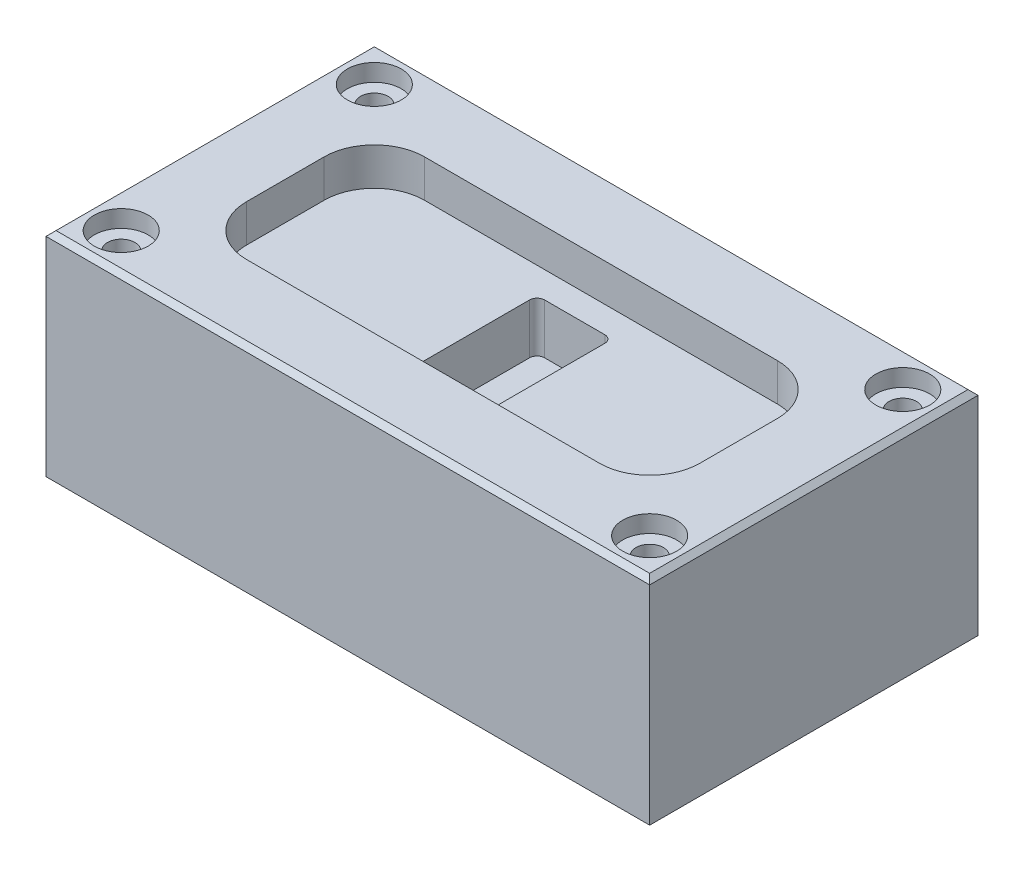
from build123d import *

# Parameters (mm, degrees)
SKETCH3_W                                = 240.765342714
SKETCH3_H                                = 130.947670476
BOSS_EXTRUDE2_DEPTH                      = 85
SKETCH4_W                                = 180.765342714
SKETCH4_H                                = 70.947670476
CUT_EXTRUDE1_DEPTH                       = 15
CBORE_FOR_M10_HEX_HEAD_BOLT1_D           = 11
CBORE_FOR_M10_HEX_HEAD_BOLT1_DEPTH       = 20
CBORE_FOR_M10_HEX_HEAD_BOLT1_CBORE_D     = 21.48
CBORE_FOR_M10_HEX_HEAD_BOLT1_CBORE_DEPTH = 6.85
CBORE_FOR_M10_HEX_HEAD_BOLT1_TIP         = 3.304733405
FILLET1_R                                = 20
CHAMFER1_SIZE                            = 2
CUT_EXTRUDE2_DEPTH                       = 20


with BuildPart() as part:
    # Sketch3 → Boss-Extrude2 (new body)
    with BuildSketch(Plane(origin=(0, 0, 0), x_dir=(1, 0, 0), z_dir=(0, 1, 0))):
        Rectangle(SKETCH3_W, SKETCH3_H)
    extrude(amount=BOSS_EXTRUDE2_DEPTH)

    # Sketch4 → Cut-Extrude1 (cut)
    with BuildSketch(Plane(origin=(0, 85, 0), x_dir=(1, 0, 0), z_dir=(0, 1, 0))):
        Rectangle(SKETCH4_W, SKETCH4_H)
    extrude(amount=-CUT_EXTRUDE1_DEPTH, mode=Mode.SUBTRACT)

    # CBORE for M10 Hex Head Bolt1
    with Locations(Plane(origin=(-105.382671357, 85, -50.473835238), x_dir=(0, 0, 1), z_dir=(0, 1, 0))):
        with Locations((0, 0), (100.947670476, 0), (0, 210.765342714), (100.947670476, 210.765342714)):
            CounterBoreHole(CBORE_FOR_M10_HEX_HEAD_BOLT1_D / 2, CBORE_FOR_M10_HEX_HEAD_BOLT1_CBORE_D / 2, CBORE_FOR_M10_HEX_HEAD_BOLT1_CBORE_DEPTH, depth=CBORE_FOR_M10_HEX_HEAD_BOLT1_DEPTH)
            with Locations((0, 0, -(CBORE_FOR_M10_HEX_HEAD_BOLT1_DEPTH + CBORE_FOR_M10_HEX_HEAD_BOLT1_TIP / 2))):  # 118° drill point
                Cone(0, CBORE_FOR_M10_HEX_HEAD_BOLT1_D / 2, CBORE_FOR_M10_HEX_HEAD_BOLT1_TIP, mode=Mode.SUBTRACT)

    # Fillet1
    fillet1_edges = [part.edges().sort_by_distance(p)[0] for p in [
        (90.382671357, 77.5, 35.473835238),
        (-90.382671357, 77.5, 35.473835238),
        (-90.382671357, 77.5, -35.473835238),
        (90.382671357, 77.5, -35.473835238),
    ]]
    fillet(fillet1_edges, radius=FILLET1_R)

    # Chamfer1
    chamfer1_edges = [part.edges().sort_by_distance(p)[0] for p in [
        (-120.382671357, 85, 0),
        (0, 85, 65.473835238),
        (120.382671357, 85, 0),
        (0, 85, -65.473835238),
    ]]
    chamfer(chamfer1_edges, length=CHAMFER1_SIZE)

    # Sketch7 → Cut-Extrude2 (cut)
    with BuildSketch(Plane(origin=(0, 70, 0), x_dir=(1, 0, 0), z_dir=(0, 1, 0))):
        with BuildLine():
            Line((-12, -25), (12, -25))
            ThreePointArc((12, -25), (14.121320344, -24.121320344), (15, -22))
            Line((15, -22), (15, 22))
            ThreePointArc((15, 22), (14.121320344, 24.121320344), (12, 25))
            Line((12, 25), (-12, 25))
            ThreePointArc((-12, 25), (-14.121320344, 24.121320344), (-15, 22))
            Line((-15, 22), (-15, -22))
            ThreePointArc((-15, -22), (-14.121320344, -24.121320344), (-12, -25))
        make_face()
    extrude(amount=-CUT_EXTRUDE2_DEPTH, mode=Mode.SUBTRACT)


solid = part.part
